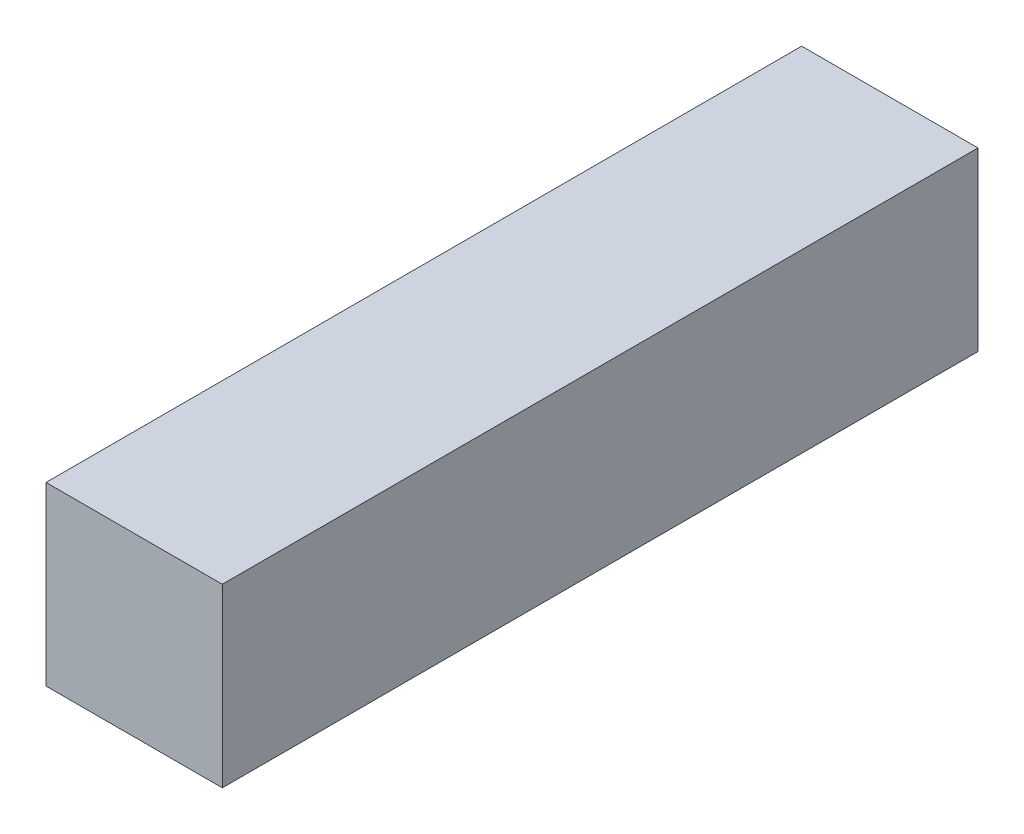
from build123d import *

# Parameters (mm, degrees)
SKETCH_1_W      = 7
SKETCH_1_H      = 7
EXTRUDE_1_DEPTH = 30


with BuildPart() as part:
    # Эскиз1 → Бобышка-Вытянуть1 (new body)
    with BuildSketch(Plane.XY):
        with Locations((-3.5, 3.5)):
            Rectangle(SKETCH_1_W, SKETCH_1_H)
    extrude(amount=-EXTRUDE_1_DEPTH)


solid = part.part
